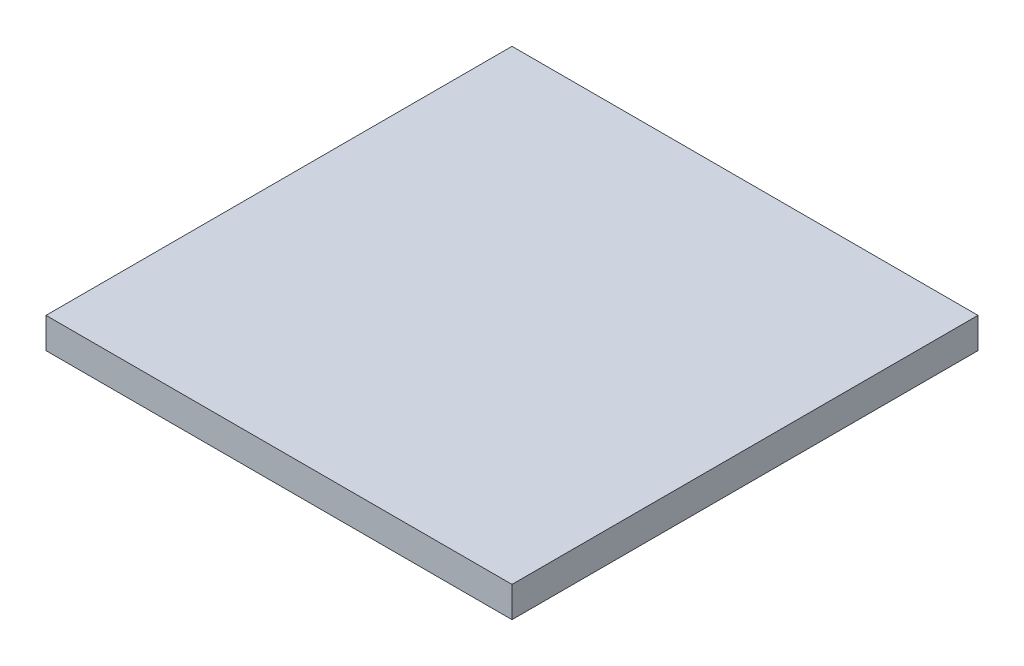
from build123d import *

# Parameters (mm, degrees)
SKETCH1_W           = 152.4
SKETCH1_H           = 152.4
BOSS_EXTRUDE1_DEPTH = 10


with BuildPart() as part:
    # Sketch1 → Boss-Extrude1 (new body)
    with BuildSketch(Plane(origin=(0, 0, 0), x_dir=(1, 0, 0), z_dir=(0, 1, 0))):
        Rectangle(SKETCH1_W, SKETCH1_H)
    extrude(amount=BOSS_EXTRUDE1_DEPTH)


solid = part.part
